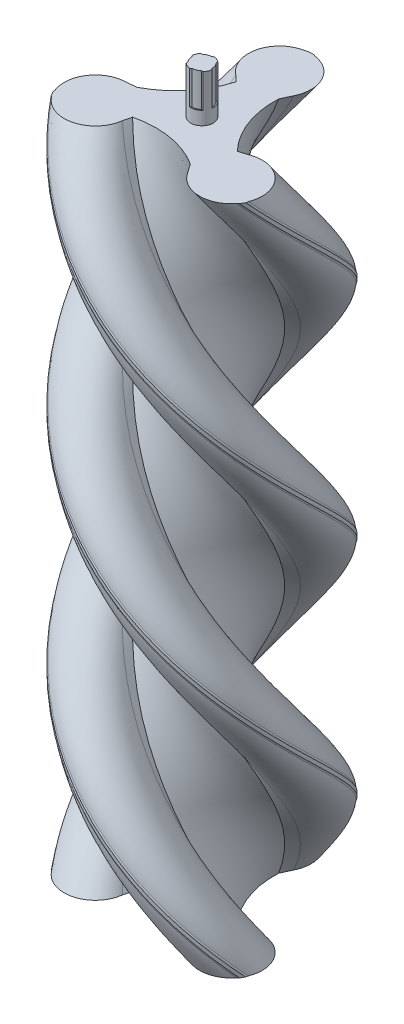
from build123d import *

# Parameters (mm, degrees)
SWEEP1_PITCH             = 300
SWEEP1_HEIGHT            = 300
SWEEP1_RADIUS            = 49.671203416
SWEEP1_START_ANGLE       = 90
CIRPATTERN1_COUNT        = 3
SKETCH4_R                = 5
BOSS_EXTRUDE1_DEPTH      = 20
BOSS_EXTRUDE1_DEPTH_BACK = 321
CUT_EXTRUDE1_DEPTH       = 15


with BuildPart() as part:
    # Sweep1: sweep along a helix
    with BuildLine() as sweep1_path:
        add(Helix(SWEEP1_PITCH, SWEEP1_HEIGHT, SWEEP1_RADIUS, center=(0, 0, 0), direction=(0, 1, 0), lefthand=True, mode=Mode.PRIVATE).rotate(Axis((0, 0, 0), (0, 1, 0)), SWEEP1_START_ANGLE))
    # Sketch1 → Sweep1 (sweep)
    with BuildSketch(Plane(origin=(0, 0, 0), x_dir=(1, 0, 0), z_dir=(0, 1, 0))):
        with BuildLine():
            Line((-5.663744237, 20.939275956), (0, 0))
            Line((0, 0), (21.482154171, -5.701736423))
            ThreePointArc((21.482154171, -5.701736423), (12.787765709, 8.019669684), (10.266511299, 24.066870451))
            Line((10.266511299, 24.066870451), (12.382014873, 28.597283747))
            ThreePointArc((12.382014873, 28.597283747), (12.282706121, 41.358085955), (1.871276603, 48.737115066))
            Line((1.871276603, 48.737115066), (0.871276603, 49.080708605))
            Line((0.871276603, 49.080708605), (-1.128723397, 49.080708605))
            Line((-1.128723397, 49.080708605), (-2.128723397, 48.737115066))
            ThreePointArc((-2.128723397, 48.737115066), (-13.688896207, 38.362333707), (-8.556656544, 23.701712994))
            Line((-8.556656544, 23.701712994), (-5.663744237, 20.939275956))
        make_face()
    sweep(path=sweep1_path.line, is_frenet=True)


with BuildPart() as cirpattern1_1:
    # CirPattern1: pattern copy
    add(part.part.rotate(Axis((0, 150, 0), (0, 1, 0)), 1 * 360 / CIRPATTERN1_COUNT))


with BuildPart() as cirpattern1_2:
    # CirPattern1: pattern copy
    add(part.part.rotate(Axis((0, 150, 0), (0, 1, 0)), 2 * 360 / CIRPATTERN1_COUNT))


with BuildPart() as part_1:
    add(part.part)

    add(cirpattern1_1.part)  # Boss-Extrude1 merges CirPattern1_1

    add(cirpattern1_2.part)  # Boss-Extrude1 merges CirPattern1_2
    # Sketch4 → Boss-Extrude1 (add, two sides)
    with BuildSketch(Plane(origin=(0, 0, 0), x_dir=(-1, 0, 0), z_dir=(0, -1, 0))) as boss_extrude1_sk:
        Circle(SKETCH4_R)
    extrude(amount=BOSS_EXTRUDE1_DEPTH)
    extrude(boss_extrude1_sk.sketch, amount=-BOSS_EXTRUDE1_DEPTH_BACK)

    # Sketch5 → Cut-Extrude1 (cut)
    with BuildSketch(Plane(origin=(0, 321, 0), x_dir=(1, 0, 0), z_dir=(0, 1, 0))):
        with BuildLine():
            ThreePointArc((0.542420563, 4.970490915), (-1.820635464, 4.656746343), (-3.769863276, 3.28452902))
            Line((-3.769863276, 3.28452902), (-3.016267135, 3.339480884))
            ThreePointArc((-3.016267135, 3.339480884), (-1.636238049, 4.191983427), (-0.043599757, 4.49978878))
            Line((-0.043599757, 4.49978878), (0.542420563, 4.970490915))
        make_face()
        with BuildLine():
            ThreePointArc((5, 0), (4.550969408, 2.070912227), (3.28452902, 3.769863276))
            Line((3.28452902, 3.769863276), (3.339480884, 3.016267135))
            ThreePointArc((3.339480884, 3.016267135), (4.191983427, 1.636238049), (4.49978878, 0.043599757))
            Line((4.49978878, 0.043599757), (4.970490915, -0.542420563))
            ThreePointArc((4.970490915, -0.542420563), (4.992617278, -0.271611328), (5, 0))
        make_face()
        with BuildLine():
            Line((0.043599757, -4.49978878), (-0.542420563, -4.970490915))
            ThreePointArc((-0.542420563, -4.970490915), (1.820635464, -4.656746343), (3.769863276, -3.28452902))
            Line((3.769863276, -3.28452902), (3.016267135, -3.339480884))
            ThreePointArc((3.016267135, -3.339480884), (1.636238049, -4.191983427), (0.043599757, -4.49978878))
        make_face()
        with BuildLine():
            Line((-4.49978878, -0.043599757), (-4.970490915, 0.542420563))
            ThreePointArc((-4.970490915, 0.542420563), (-4.656746343, -1.820635464), (-3.28452902, -3.769863276))
            Line((-3.28452902, -3.769863276), (-3.339480884, -3.016267135))
            ThreePointArc((-3.339480884, -3.016267135), (-4.191983427, -1.636238049), (-4.49978878, -0.043599757))
        make_face()
    extrude(amount=-CUT_EXTRUDE1_DEPTH, mode=Mode.SUBTRACT)


solid = part_1.part
